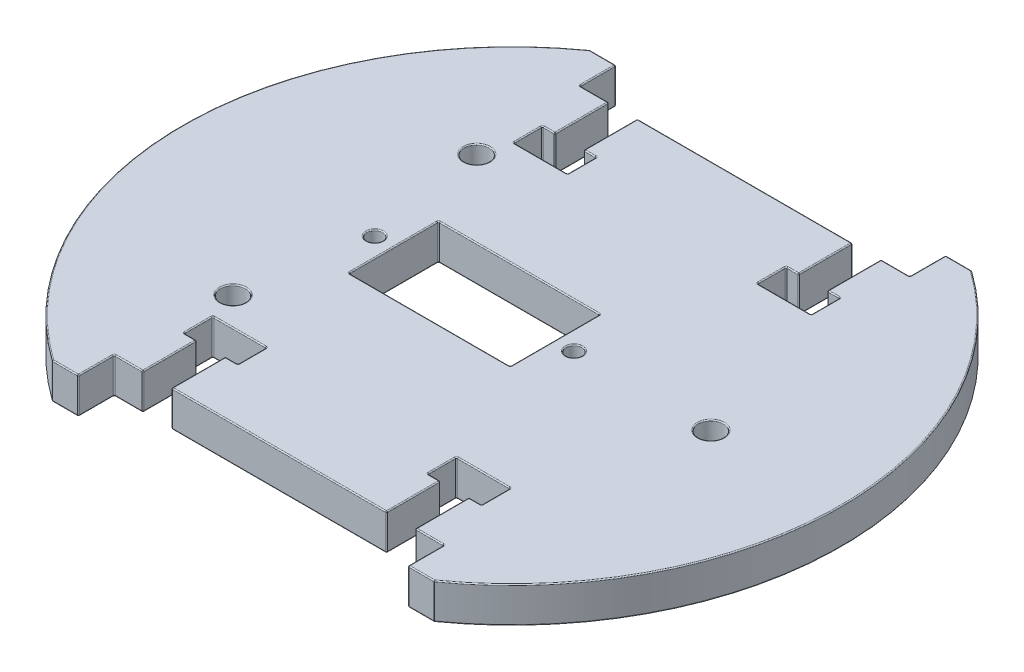
from build123d import *

# Parameters (mm, degrees)
SZKIC1_R                    = 1.1
SZKIC1_R_2                  = 1.75
SZKIC1_W                    = 22.5
SZKIC1_H                    = 12.5
DODANIE_WYCI_GNI_CIE1_DEPTH = 5
SZKIC3_W                    = 4
SZKIC3_H                    = 7.5
SZKIC3_W_2                  = 7.5
SZKIC3_H_2                  = 4
WYTNIJ_WYCI_GNI_CIE1_DEPTH  = 6
ZAOKR_GLENIE1_R             = 0.15


with BuildPart() as part:
    # Szkic1 → Dodanie-wyciągnięcie1 (new body)
    with BuildSketch(Plane(origin=(0, 0, 0), x_dir=(1, 0, 0), z_dir=(0, 1, 0))):
        with BuildLine():
            Line((-26.64113361, 37.5), (-23, 37.5))
            Line((-23, 37.5), (-23, 32.5))
            Line((-23, 32.5), (23, 32.5))
            Line((23, 32.5), (23, 37.5))
            Line((23, 37.5), (26.64113361, 37.5))
            ThreePointArc((26.64113361, 37.5), (46, 0), (26.64113361, -37.5))
            Line((26.64113361, -37.5), (23, -37.5))
            Line((23, -37.5), (23, -32.5))
            Line((23, -32.5), (-23, -32.5))
            Line((-23, -32.5), (-23, -37.5))
            Line((-23, -37.5), (-26.64113361, -37.5))
            ThreePointArc((-26.64113361, -37.5), (-46, 0), (-26.64113361, 37.5))
        make_face()
        with Locations((8.65, 0)):
            Circle(SZKIC1_R, mode=Mode.SUBTRACT)
        with Locations((-19.15, 0)):
            Circle(SZKIC1_R, mode=Mode.SUBTRACT)
        with Locations((27.75, 0)):
            Circle(SZKIC1_R_2, mode=Mode.SUBTRACT)
        with Locations((-21.93, 17)):
            Circle(SZKIC1_R_2, mode=Mode.SUBTRACT)
        with Locations((-21.93, -17)):
            Circle(SZKIC1_R_2, mode=Mode.SUBTRACT)
        with Locations((-5.25, 0)):
            Rectangle(SZKIC1_W, SZKIC1_H, mode=Mode.SUBTRACT)
    extrude(amount=DODANIE_WYCI_GNI_CIE1_DEPTH)

    # Szkic3 → Wytnij-wyciągnięcie1 (cut, through all)
    with BuildSketch(Plane(origin=(0, 5, 0), x_dir=(1, 0, 0), z_dir=(0, 1, 0))):
        with Locations((-17, 28.75)):
            Rectangle(SZKIC3_W, SZKIC3_H)
        with Locations((-17, 23)):
            Rectangle(SZKIC3_W_2, SZKIC3_H_2)
        with Locations((17, 23)):
            Rectangle(SZKIC3_W_2, SZKIC3_H_2)
        with Locations((17, 28.75)):
            Rectangle(SZKIC3_W, SZKIC3_H)
        with Locations((17, -28.75)):
            Rectangle(SZKIC3_W, SZKIC3_H)
        with Locations((17, -23)):
            Rectangle(SZKIC3_W_2, SZKIC3_H_2)
        with Locations((-17, -23)):
            Rectangle(SZKIC3_W_2, SZKIC3_H_2)
        with Locations((-17, -28.75)):
            Rectangle(SZKIC3_W, SZKIC3_H)
    extrude(amount=-WYTNIJ_WYCI_GNI_CIE1_DEPTH, mode=Mode.SUBTRACT)

    # Zaokrąglenie1
    zaokr_glenie1_edges = [part.edges().sort_by_distance(p)[0] for p in [
        (46, 5, 0),
        (-19, 2.5, -32.5),
        (-15, 0, -28.75),
        (-15, 2.5, -32.5),
        (-19, 5, -28.75),
        (-19, 2.5, -25),
        (-14.125, 0, -25),
        (-20.75, 0, -23),
        (-19.875, 0, -25),
        (-19, 0, -28.75),
        (-17, 5, -21),
        (-13.25, 5, -23),
        (-15, 5, -28.75),
        (-17, 0, -21),
        (-13.25, 2.5, -21),
        (-20.75, 5, -23),
        (-20.75, 2.5, -21),
        (-13.25, 0, -23),
        (-13.25, 2.5, -25),
        (-15, 2.5, -25),
        (-14.125, 5, -25),
        (-20.75, 2.5, -25),
        (-19.875, 5, -25),
        (-21, 0, 32.5),
        (-23, 0, 35),
        (-17, 5, 21),
        (-20.75, 2.5, 21),
        (-13.25, 5, 23),
        (-13.25, 2.5, 21),
        (-20.75, 0, 23),
        (-20.75, 2.5, 25),
        (-20.75, 5, 23),
        (-19.875, 5, 25),
        (-19, 5, 28.75),
        (-14.125, 5, 25),
        (-17, 0, 21),
        (-13.25, 0, 23),
        (-15, 0, 28.75),
        (-24.820566805, 0, 37.5),
        (-19.875, 0, 25),
        (-19, 2.5, 25),
        (-14.125, 0, 25),
        (-13.25, 2.5, 25),
        (-15, 2.5, 32.5),
        (-19, 0, 28.75),
        (-19, 2.5, 32.5),
        (-15, 5, 28.75),
        (-15, 2.5, 25),
        (-46, 0, 0),
        (17, 0, 21),
        (13.25, 2.5, 21),
        (-24.820566805, 0, -37.5),
        (20.75, 5, 23),
        (20.75, 2.5, 21),
        (13.25, 0, 23),
        (13.25, 2.5, 25),
        (17, 5, 21),
        (13.25, 5, 23),
        (15, 5, 28.75),
        (20.75, 0, 23),
        (19.875, 0, 25),
        (19, 0, 28.75),
        (14.125, 0, 25),
        (15, 2.5, 25),
        (14.125, 5, 25),
        (20.75, 2.5, 25),
        (19.875, 5, 25),
        (-23, 0, -35),
        (19, 2.5, 32.5),
        (15, 0, 28.75),
        (15, 2.5, 32.5),
        (19, 5, 28.75),
        (24.820566805, 5, -37.5),
        (19, 2.5, 25),
        (21, 0, -32.5),
        (15, 5, -28.75),
        (15, 2.5, -25),
        (15, 2.5, -32.5),
        (19, 0, -28.75),
        (19, 2.5, -32.5),
        (17, 0, -21),
        (23, 0, -35),
        (13.25, 0, -23),
        (15, 0, -28.75),
        (14.125, 5, -25),
        (20.75, 5, -23),
        (19.875, 5, -25),
        (19, 5, -28.75),
        (17, 5, -21),
        (20.75, 2.5, -21),
        (13.25, 5, -23),
        (13.25, 2.5, -21),
        (20.75, 0, -23),
        (20.75, 2.5, -25),
        (19.875, 0, -25),
        (19, 2.5, -25),
        (14.125, 0, -25),
        (24.820566805, 0, -37.5),
        (13.25, 2.5, -25),
        (46, 0, 0),
        (24.820566805, 0, 37.5),
        (23, 0, 35),
        (23, 5, -35),
        (21, 5, -32.5),
        (23, 2.5, 32.5),
        (-23, 2.5, 32.5),
        (-23, 2.5, 37.5),
        (-26.64113361, 2.5, 37.5),
        (-26.64113361, 2.5, -37.5),
        (-23, 2.5, -37.5),
        (-23, 2.5, -32.5),
        (23, 2.5, -32.5),
        (23, 2.5, -37.5),
        (26.64113361, 2.5, -37.5),
        (26.64113361, 2.5, 37.5),
        (23, 2.5, 37.5),
        (-23, 5, -35),
        (-24.820566805, 5, -37.5),
        (-46, 5, 0),
        (-24.820566805, 5, 37.5),
        (6, 0, 0),
        (6, 2.5, 6.25),
        (-5.25, 0, -6.25),
        (6, 2.5, -6.25),
        (-16.5, 0, 0),
        (-16.5, 2.5, -6.25),
        (-5.25, 0, 6.25),
        (-16.5, 2.5, 6.25),
        (-23, 5, 35),
        (6, 5, 0),
        (-5.25, 5, -6.25),
        (-16.5, 5, 0),
        (-5.25, 5, 6.25),
        (-21, 5, 32.5),
        (23, 5, 35),
        (7.55, 0, 0),
        (7.55, 5, 0),
        (-20.25, 0, 0),
        (-20.25, 5, 0),
        (26, 0, 0),
        (26, 5, 0),
        (-23.68, 0, -17),
        (-23.68, 5, -17),
        (-23.68, 0, 17),
        (-23.68, 5, 17),
        (24.820566805, 5, 37.5),
        (0, 0, 32.5),
        (21, 0, 32.5),
        (0, 5, 32.5),
        (21, 5, 32.5),
        (0, 0, -32.5),
        (-21, 0, -32.5),
        (0, 5, -32.5),
        (-21, 5, -32.5),
    ]]
    fillet(zaokr_glenie1_edges, radius=ZAOKR_GLENIE1_R)


solid = part.part
